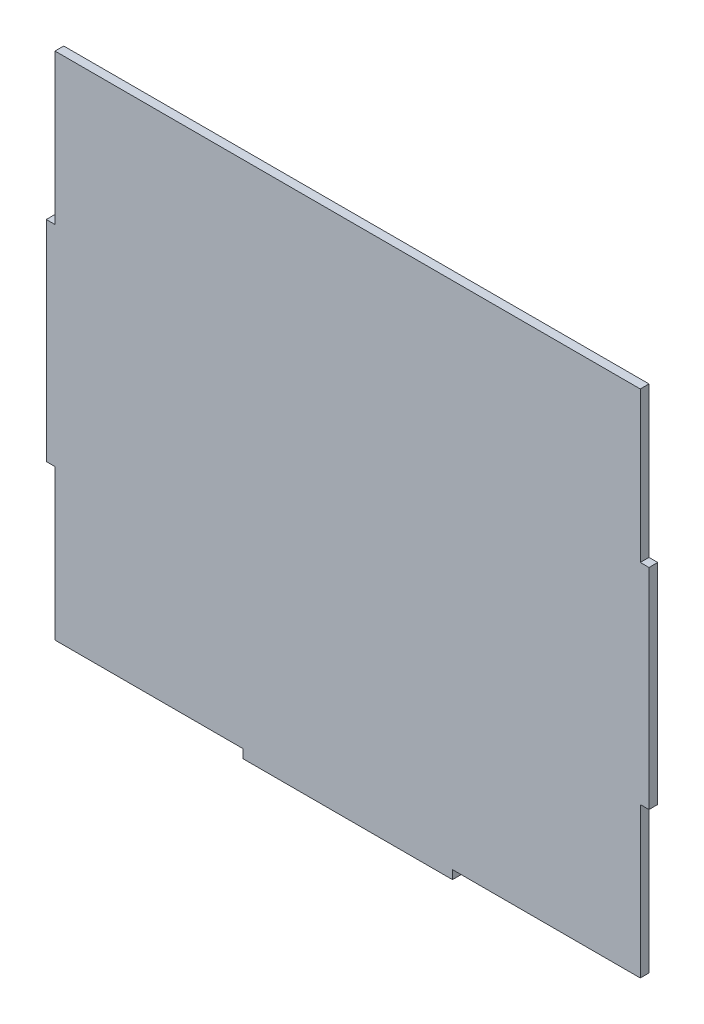
from build123d import *

# Parameters (mm, degrees)
SKETCH1_W           = 212.725
SKETCH1_H           = 185.42
BOSS_EXTRUDE1_DEPTH = 3.175
SKETCH5_W           = 3.175
SKETCH5_H           = 76.2
BOSS_EXTRUDE2_DEPTH = 3.175
SKETCH6_W           = 76.2
SKETCH6_H           = 3.175
BOSS_EXTRUDE3_DEPTH = 3.175


with BuildPart() as part:
    # Sketch1 → Boss-Extrude1 (new body)
    with BuildSketch(Plane.XY):
        Rectangle(SKETCH1_W, SKETCH1_H)
    extrude(amount=BOSS_EXTRUDE1_DEPTH)

    # Sketch5 → Boss-Extrude2 (add)
    with BuildSketch(Plane(origin=(0, 0, 0), x_dir=(-1, 0, 0), z_dir=(0, 0, -1))):
        with Locations((-107.95, 0)):
            Rectangle(SKETCH5_W, SKETCH5_H)
        with Locations((107.95, 0)):
            Rectangle(SKETCH5_W, SKETCH5_H)
    extrude(amount=-BOSS_EXTRUDE2_DEPTH)

    # Sketch6 → Boss-Extrude3 (add)
    with BuildSketch(Plane(origin=(0, 0, 0), x_dir=(-1, 0, 0), z_dir=(0, 0, -1))):
        with Locations((0, -94.2975)):
            Rectangle(SKETCH6_W, SKETCH6_H)
    extrude(amount=-BOSS_EXTRUDE3_DEPTH)


solid = part.part
